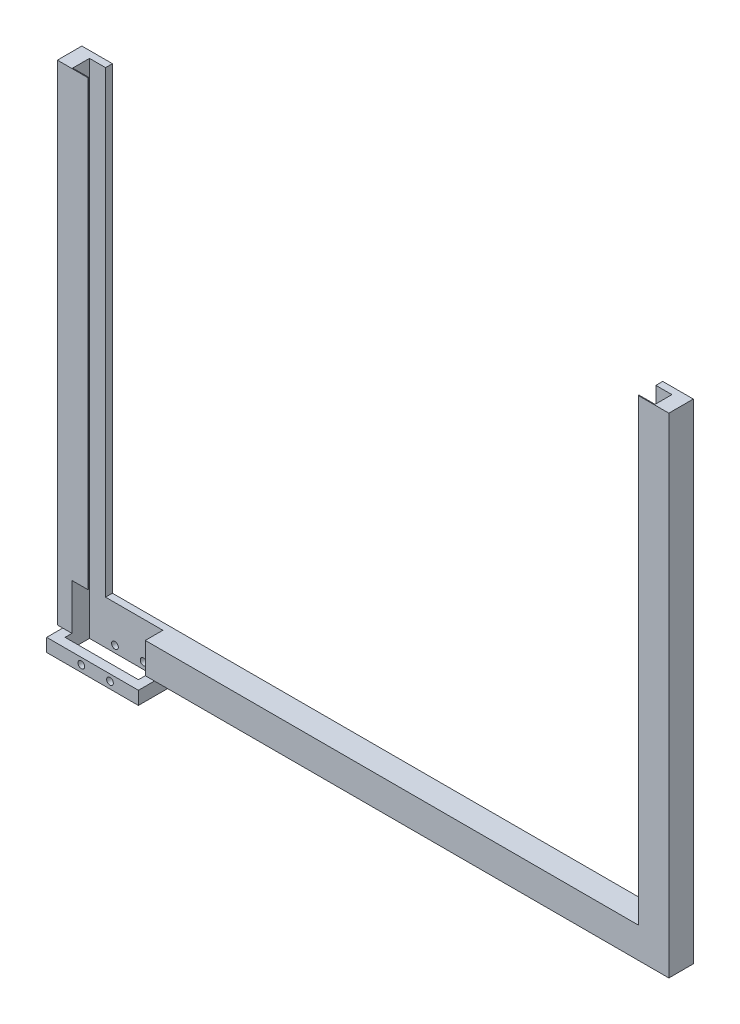
from build123d import *

# Parameters (mm, degrees)
CROQUIS1_W              = 200
CROQUIS1_H              = 170
SALIENTE_EXTRUIR1_DEPTH = 10
SALIENTE_EXTRUIR2_DEPTH = 150
CROQUIS3_W              = 90
CROQUIS3_H              = 10
SALIENTE_EXTRUIR3_DEPTH = 100
CROQUIS4_W              = 5.25
CROQUIS4_H              = 5.5
CORTAR_EXTRUIR1_DEPTH   = 170
CROQUIS7_W              = 90
CROQUIS7_H              = 10
SALIENTE_EXTRUIR4_DEPTH = 5
CORTAR_EXTRUIR3_DEPTH   = 10
CORTAR_EXTRUIR4_DEPTH   = 30
CORTAR_EXTRUIR5_DEPTH   = 5
CROQUIS10_W             = 30
CROQUIS10_H             = 13.5
CROQUIS10_W_2           = 24
CROQUIS10_H_2           = 8
SALIENTE_EXTRUIR5_DEPTH = 4.3
CROQUIS11_R             = 1.1
CORTAR_EXTRUIR6_DEPTH   = 14.3
CROQUIS12_R             = 1.75
CORTAR_EXTRUIR7_DEPTH   = 6.4
CROQUIS13_R             = 1.7
CORTAR_EXTRUIR8_DEPTH   = 5
CROQUIS14_W             = 0.3
CROQUIS14_H             = 10
CORTAR_EXTRUIR9_DEPTH   = 5
SALIENTE_EXTRUIR6_DEPTH = 5
CROQUIS16_W             = 200
CROQUIS16_H             = 160
CORTAR_EXTRUIR10_DEPTH  = 162
CROQUIS16_2_W           = 200
CROQUIS16_2_H           = 160
CORTAR_EXTRUIR11_DEPTH  = 162


with BuildPart() as part:
    # Croquis1 → Saliente-Extruir1 (new body)
    with BuildSketch(Plane(origin=(0, 0, 0), x_dir=(1, 0, 0), z_dir=(0, 1, 0))):
        Rectangle(CROQUIS1_W, CROQUIS1_H)
    extrude(amount=SALIENTE_EXTRUIR1_DEPTH)

    # Croquis2 → Saliente-Extruir2 (add)
    with BuildSketch(Plane(origin=(0, 10, 0), x_dir=(1, 0, 0), z_dir=(0, 1, 0))):
        Polygon((-100, 85), (-100, -85), (-30.21, -85), (-30.21, -75), (-90, -75), (-90, 85), align=None)
        Polygon((59.79, -75), (59.79, -85), (100, -85), (100, 85), (90, 85), (90, -75), align=None)
    extrude(amount=SALIENTE_EXTRUIR2_DEPTH)

    # Croquis3 → Saliente-Extruir3 (add)
    with BuildSketch(Plane(origin=(0, 160, 0), x_dir=(1, 0, 0), z_dir=(0, 1, 0))):
        with Locations((14.79, -80)):
            Rectangle(CROQUIS3_W, CROQUIS3_H)
    extrude(amount=-SALIENTE_EXTRUIR3_DEPTH)

    # Croquis4 → Cortar-Extruir1 (cut)
    with BuildSketch(Plane(origin=(0, 10, 65), x_dir=(-1, 0, 0), z_dir=(0, 1, 0))):
        with Locations((92.625, -145)):
            Rectangle(CROQUIS4_W, CROQUIS4_H)
        with Locations((-92.625, -145)):
            Rectangle(CROQUIS4_W, CROQUIS4_H)
    extrude(amount=CORTAR_EXTRUIR1_DEPTH, mode=Mode.SUBTRACT)

    # Croquis7 → Saliente-Extruir4 (add)
    with BuildSketch(Plane.XY.offset(85)):
        with Locations((14.79, 65)):
            Rectangle(CROQUIS7_W, CROQUIS7_H)
    extrude(amount=SALIENTE_EXTRUIR4_DEPTH)

    # Croquis8 → Cortar-Extruir3 (cut)
    with BuildSketch(Plane(origin=(0, 160, 0), x_dir=(1, 0, 0), z_dir=(0, 1, 0))):
        Polygon((98, -83), (98, 70), (92, 70), (92, -77), (-92, -77), (-92, 70), (-98, 70), (-98, -83), align=None)
    extrude(amount=-CORTAR_EXTRUIR3_DEPTH, mode=Mode.SUBTRACT)

    # Croquis9 → Cortar-Extruir4 (cut)
    with BuildSketch(Plane(origin=(0, 10, 0), x_dir=(1, 0, 0), z_dir=(0, 1, 0))):
        Polygon((-95.25, 77.25), (-95.25, 82.75), (-71.25, 82.75), (-71.25, 77.25), (-71.25, 74.75), (-95.25, 74.75), align=None)
    extrude(amount=-CORTAR_EXTRUIR4_DEPTH, mode=Mode.SUBTRACT)

    # Croquis9_2 → Cortar-Extruir5 (cut)
    with BuildSketch(Plane(origin=(0, 10, 0), x_dir=(1, 0, 0), z_dir=(0, 1, 0))):
        Polygon((-95.25, 77.25), (-95.25, 82.75), (-71.25, 82.75), (-71.25, 77.25), (-71.25, 74.75), (-95.25, 74.75), align=None)
    extrude(amount=CORTAR_EXTRUIR5_DEPTH, mode=Mode.SUBTRACT)

    # Croquis10 → Saliente-Extruir5 (add)
    with BuildSketch(Plane.XZ):
        with Locations((-83.25, -78.5)):
            Rectangle(CROQUIS10_W, CROQUIS10_H)
        with Locations((-83.25, -78.75)):
            Rectangle(CROQUIS10_W_2, CROQUIS10_H_2, mode=Mode.SUBTRACT)
    extrude(amount=SALIENTE_EXTRUIR5_DEPTH)

    # Croquis11 → Cortar-Extruir6 (cut)
    with BuildSketch(Plane.XY.offset(-71.75)):
        with Locations((-77.55, -2.1)):
            Circle(CROQUIS11_R)
        with Locations((-86.93, -2.1)):
            Circle(CROQUIS11_R)
    extrude(amount=-CORTAR_EXTRUIR6_DEPTH, mode=Mode.SUBTRACT)

    # Croquis12 → Cortar-Extruir7 (cut)
    with BuildSketch(Plane.XZ):
        with Locations((-91.5, -55)):
            Circle(CROQUIS12_R)
        with Locations((18.5, -55)):
            Circle(CROQUIS12_R)
        with Locations((-91.5, 55)):
            Circle(CROQUIS12_R)
        with Locations((18.5, 55)):
            Circle(CROQUIS12_R)
    extrude(amount=-CORTAR_EXTRUIR7_DEPTH, mode=Mode.SUBTRACT)

    # Croquis13 → Cortar-Extruir8 (cut)
    with BuildSketch(Plane.XY.offset(85)):
        with Locations((-50.21, 24)):
            Circle(CROQUIS13_R)
        with Locations((79.79, 24)):
            Circle(CROQUIS13_R)
    extrude(amount=-CORTAR_EXTRUIR8_DEPTH, mode=Mode.SUBTRACT)

    # Croquis14 → Cortar-Extruir9 (cut)
    with BuildSketch(Plane.XY.offset(90)):
        with Locations((-30.06, 65)):
            Rectangle(CROQUIS14_W, CROQUIS14_H)
        with Locations((59.64, 65)):
            Rectangle(CROQUIS14_W, CROQUIS14_H)
    extrude(amount=-CORTAR_EXTRUIR9_DEPTH, mode=Mode.SUBTRACT)

    # Croquis15 → Saliente-Extruir6 (add)
    with BuildSketch(Plane.XY.offset(85)):
        Polygon((14.79, 0), (94.79, 0), (94.79, 4.8), (14.79, 4.8), (-65.21, 4.8), (-65.21, 0), align=None)
    extrude(amount=SALIENTE_EXTRUIR6_DEPTH)

    # Croquis16 → Cortar-Extruir10 (cut)
    with BuildSketch(Plane.XY.offset(85)):
        with Locations((0, 80)):
            Rectangle(CROQUIS16_W, CROQUIS16_H)
    extrude(amount=-CORTAR_EXTRUIR10_DEPTH, mode=Mode.SUBTRACT)


with BuildPart() as cortar_extruir10_piece_1:
    # of the separate pieces the step leaves, piece 1, a body of its own (cortar_extruir10_pieces)
    add(part.part.solids().sort_by_distance((-100, 160, -85))[0])


with BuildPart() as cortar_extruir10_piece_2:
    # of the separate pieces the step leaves, piece 2, a body of its own (cortar_extruir10_pieces)
    add(part.part.solids().sort_by_distance((-29.91, 60, 90))[0])


with BuildPart() as cortar_extruir10_piece_3:
    # of the separate pieces the step leaves, piece 3, a body of its own (cortar_extruir10_pieces)
    add(part.part.solids().sort_by_distance((-65.21, 4.8, 85))[0])


with BuildPart() as cortar_extruir11_tool:
    # Croquis16_2 → Cortar-Extruir11 (new body)
    with BuildSketch(Plane.XY.offset(85)):
        with Locations((0, 80)):
            Rectangle(CROQUIS16_2_W, CROQUIS16_2_H)
    extrude(amount=CORTAR_EXTRUIR11_DEPTH)


with BuildPart() as cortar_extruir10_piece_2_1:
    add(cortar_extruir10_piece_2.part)

    # Cortar-Extruir11: cut by cortar_extruir11_tool
    add(cortar_extruir11_tool.part, mode=Mode.SUBTRACT)


with BuildPart() as cortar_extruir10_piece_3_1:
    add(cortar_extruir10_piece_3.part)

    # Cortar-Extruir11: cut by cortar_extruir11_tool
    add(cortar_extruir11_tool.part, mode=Mode.SUBTRACT)


solid = cortar_extruir10_piece_1.part
